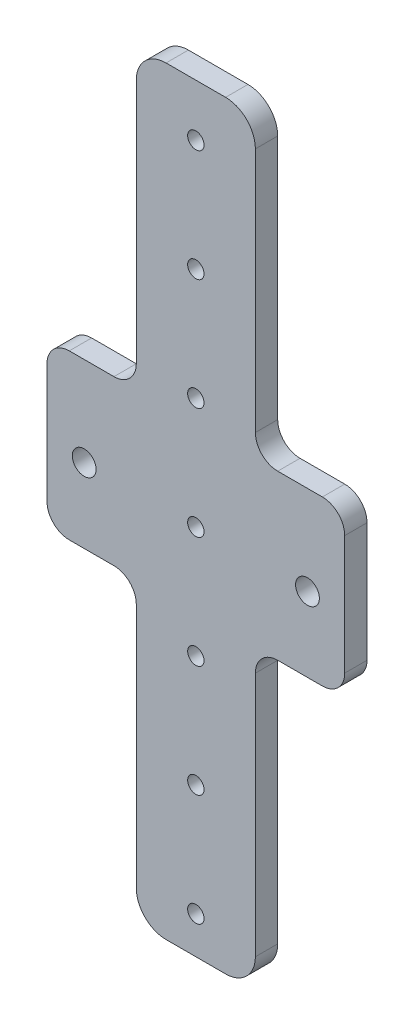
from build123d import *

# Parameters (mm, degrees)
SKETCH_1_W          = 40
SKETCH_1_H          = 150
SKETCH_1_R          = 1.6
EXTRUDE_1_DEPTH     = 3
SKETCH_2_R          = 1.1
CUT_EXTRUDE_1_DEPTH = 4
SKETCH_4_W          = 40
SKETCH_4_H          = 18
CUT_EXTRUDE_3_DEPTH = 10
SKETCH_5_W          = 40
SKETCH_5_H          = 12
EXTRUDE_2_DEPTH     = 3
SKETCH_6_R          = 1.1
CUT_EXTRUDE_4_DEPTH = 10
SKETCH_7_W          = 12
SKETCH_7_H          = 75
SKETCH_7_H_2        = 47
CUT_EXTRUDE_5_DEPTH = 10
FILLET_1_R          = 3
SKETCH_8_W          = 16
SKETCH_8_H          = 42.139164074
SKETCH_8_H_2        = 21.417935282
CUT_EXTRUDE_6_DEPTH = 10
FILLET_2_R          = 4


with BuildPart() as part:
    # 草图1 → 凸台-拉伸1 (new body)
    with BuildSketch(Plane.XY):
        Rectangle(SKETCH_1_W, SKETCH_1_H)
        with Locations((-15, 0)):
            Circle(SKETCH_1_R, mode=Mode.SUBTRACT)
        with Locations((15, 0)):
            Circle(SKETCH_1_R, mode=Mode.SUBTRACT)
    extrude(amount=EXTRUDE_1_DEPTH)

    # 草图2 → 切除-拉伸1 (cut, through all)
    with BuildSketch(Plane.XY.offset(3)):
        with Locations((0, 30)):
            Circle(SKETCH_2_R)
        with Locations((0, 45)):
            Circle(SKETCH_2_R)
        with Locations((0, 60)):
            Circle(SKETCH_2_R)
        with Locations((0, 15)):
            Circle(SKETCH_2_R)
        with Locations((0, -15)):
            Circle(SKETCH_2_R)
        Circle(SKETCH_2_R)
        with Locations((0, -30)):
            Circle(SKETCH_2_R)
        with Locations((0, -45)):
            Circle(SKETCH_2_R)
        with Locations((0, -60)):
            Circle(SKETCH_2_R)
    extrude(amount=-CUT_EXTRUDE_1_DEPTH, mode=Mode.SUBTRACT)

    # 草图4 → 切除-拉伸3 (cut)
    with BuildSketch(Plane.XY.offset(3)):
        with Locations((0, -66)):
            Rectangle(SKETCH_4_W, SKETCH_4_H)
    extrude(amount=-CUT_EXTRUDE_3_DEPTH, mode=Mode.SUBTRACT)

    # 草图5 → 凸台-拉伸2 (add)
    with BuildSketch(Plane.XY.offset(3)):
        with Locations((0, 81)):
            Rectangle(SKETCH_5_W, SKETCH_5_H)
    extrude(amount=-EXTRUDE_2_DEPTH)

    # 草图6 → 切除-拉伸4 (cut)
    with BuildSketch(Plane.XY.offset(3)):
        with Locations((0, 75)):
            Circle(SKETCH_6_R)
    extrude(amount=-CUT_EXTRUDE_4_DEPTH, mode=Mode.SUBTRACT)

    # 草图7 → 切除-拉伸5 (cut)
    with BuildSketch(Plane.XY.offset(3)):
        with Locations((-14, 49.5)):
            Rectangle(SKETCH_7_W, SKETCH_7_H)
        with Locations((-14, -33.5)):
            Rectangle(SKETCH_7_W, SKETCH_7_H_2)
        with Locations((14, -33.5)):
            Rectangle(SKETCH_7_W, SKETCH_7_H_2)
        with Locations((14, 49.5)):
            Rectangle(SKETCH_7_W, SKETCH_7_H)
    extrude(amount=-CUT_EXTRUDE_5_DEPTH, mode=Mode.SUBTRACT)

    # 圆角1
    fillet_1_edges = [part.edges().sort_by_distance(p)[0] for p in [
        (-8, 87, 1.5),
        (8, 87, 1.5),
        (-8, -57, 1.5),
        (8, -57, 1.5),
        (20, 12, 1.5),
        (8, 12, 1.5),
        (8, -10, 1.5),
        (20, -10, 1.5),
        (-20, -10, 1.5),
        (-8, -10, 1.5),
        (-20, 12, 1.5),
        (-8, 12, 1.5),
    ]]
    fillet(fillet_1_edges, radius=FILLET_1_R)

    # 草图8 → 切除-拉伸6 (cut)
    with BuildSketch(Plane.XY.offset(3)):
        with Locations((0, 73.069582037)):
            Rectangle(SKETCH_8_W, SKETCH_8_H)
        with Locations((0, -60.708967641)):
            Rectangle(SKETCH_8_W, SKETCH_8_H_2)
    extrude(amount=-CUT_EXTRUDE_6_DEPTH, mode=Mode.SUBTRACT)

    # 圆角2
    fillet_2_edges = [part.edges().sort_by_distance(p)[0] for p in [
        (8, 52, 1.5),
        (-8, 52, 1.5),
        (8, -50, 1.5),
        (-8, -50, 1.5),
    ]]
    fillet(fillet_2_edges, radius=FILLET_2_R)


solid = part.part
